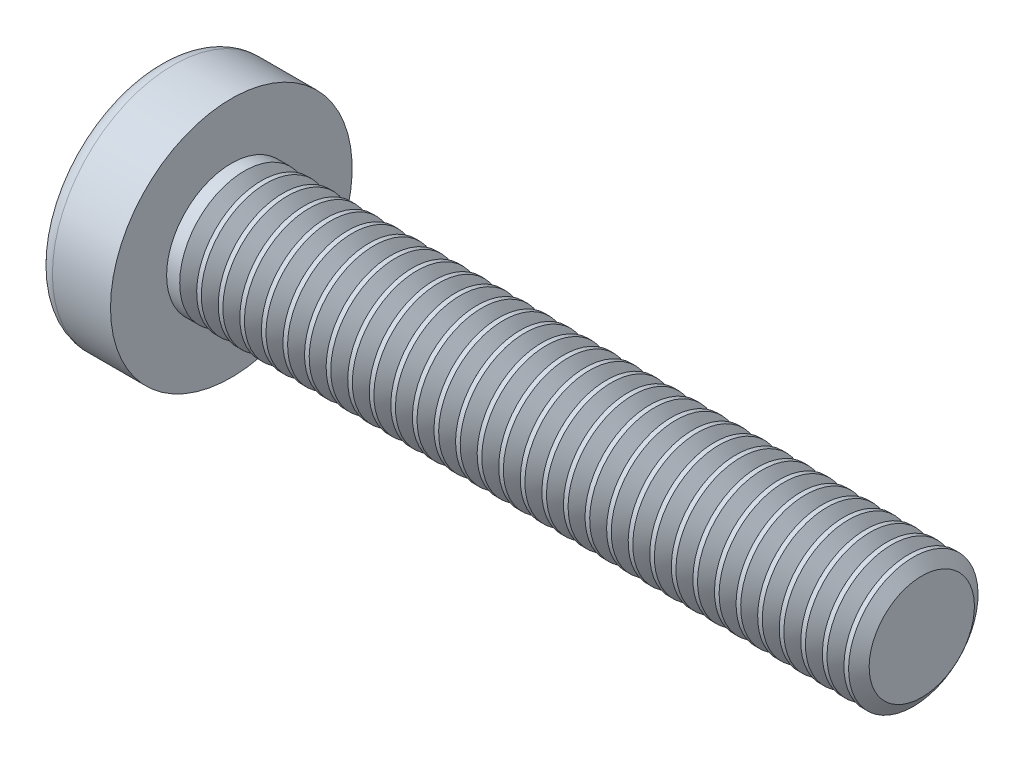
from build123d import *

# Parameters (mm, degrees)
SKETCH3_W         = 0.74
SKETCH3_H         = 2.9
SKETCH4_W         = 0.37
SKETCH4_H         = 0.37
CIRPATTERN1_COUNT = 2
CIRPATTERN1_ANGLE = 90
THDSCHPAT_COUNT   = 32
THDSCHPAT_PITCH   = 0.5


with BuildPart() as part:
    # BodySke → Base-Revolve (revolve)
    with BuildSketch(Plane.XY):
        with BuildLine():
            Line((2.4, 1.5), (2.4, 2.8))
            Line((2.4, 2.8), (1.053355856, 2.8))
            ThreePointArc((1.053355856, 2.8), (0.878072834, 2.754445324), (0.747150707, 2.629310345))
            ThreePointArc((0.747150707, 2.629310345), (0.190413403, 1.366702882), (0, 0))
            Line((0, 0), (18.4, 0))
            Line((18.4, 0), (18.4, 1.5))
            Line((18.4, 1.5), (2.4, 1.5))
        make_face()
    revolve(axis=Axis((-25.4, 0, 0), (1, 0, 0)))

    # Sketch3 → Cut-Loft1 section 0
    with BuildSketch(Plane(origin=(0, 0, 0), x_dir=(0, 0, -1), z_dir=(1, 0, 0))):
        Rectangle(SKETCH3_W, SKETCH3_H)
    # Sketch4 → Cut-Loft1 section 1
    with BuildSketch(Plane(origin=(1.76, 0, 0), x_dir=(0, 0, -1), z_dir=(1, 0, 0))):
        Rectangle(SKETCH4_W, SKETCH4_H)
    cut_loft1 = loft(mode=Mode.SUBTRACT)

    # CirPattern1: Cut-Loft1 ×2 about axis
    cirpattern1_axis = Axis((0, 0, 0), (1, 0, 0))
    for i in range(1, CIRPATTERN1_COUNT):
        add(cut_loft1.rotate(cirpattern1_axis, i * CIRPATTERN1_ANGLE / (CIRPATTERN1_COUNT - 1)), mode=Mode.SUBTRACT)

    # ThdSchSke → ThreadSchematic (revolve, cut)
    with BuildSketch(Plane.XY):
        Polygon((2.9, -1.2195), (2.703591786, -1.5), (2.703591786, -1.875), (3.096408214, -1.875), (3.096408214, -1.5), align=None)
    threadschematic = revolve(axis=Axis((-3.175, 0, 0), (1, 0, 0)), mode=Mode.SUBTRACT)

    # ThdSchPat: ThreadSchematic ×32
    with Locations(*[(i * THDSCHPAT_PITCH, 0, 0) for i in range(1, THDSCHPAT_COUNT)]):
        add(threadschematic, mode=Mode.SUBTRACT)


solid = part.part
